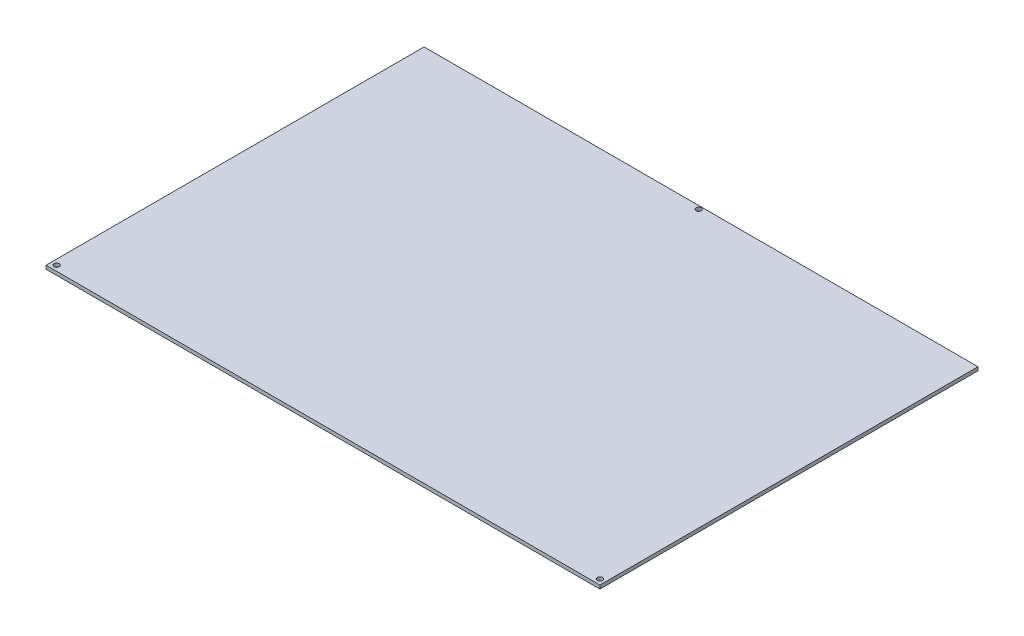
from build123d import *

# Parameters (mm, degrees)
SKETCH1_W           = 315
SKETCH1_H           = 215
BOSS_EXTRUDE1_DEPTH = 2
SKETCH2_R           = 1.5
CUT_EXTRUDE1_DEPTH  = 47
SKETCH3_R           = 1.5
CUT_EXTRUDE2_DEPTH  = 47


with BuildPart() as part:
    # Sketch1 → Boss-Extrude1 (new body)
    with BuildSketch(Plane(origin=(0, 0, 0), x_dir=(1, 0, 0), z_dir=(0, 1, 0))):
        with Locations((157.5, 107.5)):
            Rectangle(SKETCH1_W, SKETCH1_H)
    extrude(amount=BOSS_EXTRUDE1_DEPTH)

    # Sketch2 → Cut-Extrude1 (cut)
    with BuildSketch(Plane(origin=(0, 2, 0), x_dir=(1, 0, 0), z_dir=(0, 1, 0))):
        with Locations((3, 3)):
            Circle(SKETCH2_R)
        with Locations((312, 3)):
            Circle(SKETCH2_R)
    extrude(amount=-CUT_EXTRUDE1_DEPTH, mode=Mode.SUBTRACT)

    # Sketch3 → Cut-Extrude2 (cut)
    with BuildSketch(Plane(origin=(0, 2, 0), x_dir=(1, 0, 0), z_dir=(0, 1, 0))):
        with Locations((158, 213.117089456)):
            Circle(SKETCH3_R)
    extrude(amount=-CUT_EXTRUDE2_DEPTH, mode=Mode.SUBTRACT)


solid = part.part
